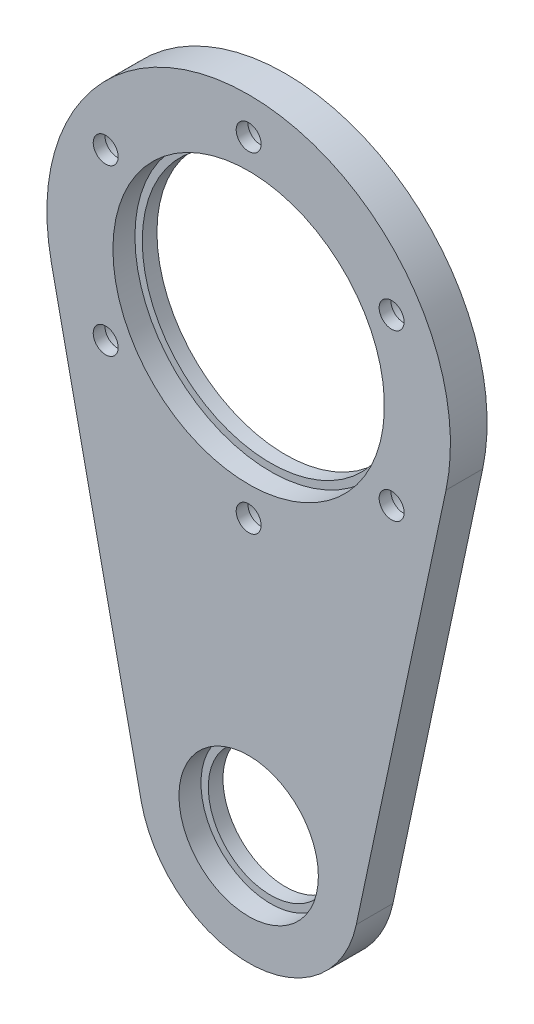
from build123d import *

# Parameters (mm, degrees)
SKETCH_2_R                   = 27.5
EXTRUDE_2_DEPTH              = 2
SKETCH_22_R                  = 10
CUT_EXTRUDE_1_DEPTH          = 2
FILLET_4_R                   = 0.2
SKETCH_54_R                  = 27.5
EXTRUDE_6_DEPTH              = 11
SKETCH_55_R                  = 18.5
CUT_EXTRUDE_2_DEPTH          = 8
HOLE_WIZARD_M4_1_D           = 4.5
HOLE_WIZARD_M4_1_CBORE_D     = 8
HOLE_WIZARD_M4_1_CBORE_DEPTH = 1
PATTERN_CIRCULAR_1_COUNT     = 3
SKETCH_59_R                  = 18.5
SKETCH_59_R_2                = 17.5
EXTRUDE_7_DEPTH              = 1
EXTRUDE_8_DEPTH              = 9
FILLET_6_R                   = 0.3
SKETCH_68_R                  = 9.5
CUT_EXTRUDE_7_DEPTH          = 7
SKETCH_69_R                  = 8.5
CUT_EXTRUDE_8_DEPTH          = 3
SKETCH_80_W                  = 72.028937147
SKETCH_80_H                  = 17.189961631
CUT_EXTRUDE_9_DEPTH          = 176.5
SKETCH_83_R                  = 18.5
SKETCH_83_R_2                = 17.5
EXTRUDE_9_DEPTH              = 2
PATTERN_CIRCULAR_2_COUNT     = 6


with BuildPart() as part:
    # 스케치2 → 보스-돌출2 (new body)
    with BuildSketch(Plane(origin=(0, 6, 0), x_dir=(1, 0, 0), z_dir=(0, 0, -1))):
        with Locations((0, 6)):
            Circle(SKETCH_2_R)
    extrude(amount=EXTRUDE_2_DEPTH)

    # 스케치22 → 컷-돌출1 (cut)
    with BuildSketch(Plane.XY):
        Circle(SKETCH_22_R)
    extrude(amount=-CUT_EXTRUDE_1_DEPTH, mode=Mode.SUBTRACT)

    # 필렛4
    fillet_4_edges = [part.edges().sort_by_distance(p)[0] for p in [
        (-10, 0, 0),
    ]]
    fillet(fillet_4_edges, radius=FILLET_4_R)

    # 스케치54 → 보스-돌출6 (add)
    with BuildSketch(Plane(origin=(0, 0, -2), x_dir=(-1, 0, 0), z_dir=(0, 0, -1))):
        Circle(SKETCH_54_R)
    extrude(amount=EXTRUDE_6_DEPTH)

    # 스케치55 → 컷-돌출2 (cut)
    with BuildSketch(Plane(origin=(0, 0, -13), x_dir=(-1, 0, 0), z_dir=(0, 0, -1))):
        Circle(SKETCH_55_R)
    extrude(amount=-CUT_EXTRUDE_2_DEPTH, mode=Mode.SUBTRACT)

    # M4 육각 소켓 머리 캡 나사용 카운터보어1 (through all)
    with Locations(Plane(origin=(0, 0, -5), x_dir=(-1, 0, 0), z_dir=(0, 0, -1))):
        with Locations((0, 6)):
            hole_wizard_m4_1 = CounterBoreHole(HOLE_WIZARD_M4_1_D / 2, HOLE_WIZARD_M4_1_CBORE_D / 2, HOLE_WIZARD_M4_1_CBORE_DEPTH)

    # 원형 패턴1: M4 육각 소켓 머리 캡 나사용 카운터보어1 ×3 about axis
    pattern_circular_1_axis = Axis((0, 0, 0), (0, 0, 1))
    for i in range(1, PATTERN_CIRCULAR_1_COUNT):
        add(hole_wizard_m4_1.rotate(pattern_circular_1_axis, i * 360 / PATTERN_CIRCULAR_1_COUNT), mode=Mode.SUBTRACT)

    # 스케치59 → 보스-돌출7 (add)
    with BuildSketch(Plane(origin=(0, 0, -5), x_dir=(-1, 0, 0), z_dir=(0, 0, -1))):
        Circle(SKETCH_59_R)
        Circle(SKETCH_59_R_2, mode=Mode.SUBTRACT)
    extrude(amount=EXTRUDE_7_DEPTH)

    # 스케치60 → 보스-돌출8 (add)
    with BuildSketch(Plane(origin=(0, 0, -13), x_dir=(-1, 0, 0), z_dir=(0, 0, -1))):
        with BuildLine():
            Line((-26.896591779, -5.729166667), (-14.670868243, -63.125))
            ThreePointArc((-14.670868243, -63.125), (0, -75), (14.670868243, -63.125))
            Line((14.670868243, -63.125), (26.896591779, -5.729166667))
            ThreePointArc((26.896591779, -5.729166667), (0, -27.5), (-26.896591779, -5.729166667))
        make_face()
    extrude(amount=-EXTRUDE_8_DEPTH)

    # 필렛6
    fillet_6_edges = [part.edges().sort_by_distance(p)[0] for p in [
        (18.5, 0, -6),
    ]]
    fillet(fillet_6_edges, radius=FILLET_6_R)

    # 스케치68 → 컷-돌출7 (cut)
    with BuildSketch(Plane.XY.offset(-4)):
        with Locations((0, -60)):
            Circle(SKETCH_68_R)
    extrude(amount=-CUT_EXTRUDE_7_DEPTH, mode=Mode.SUBTRACT)

    # 스케치69 → 컷-돌출8 (cut, through all)
    with BuildSketch(Plane.XY.offset(-11)):
        with Locations((0, -60)):
            Circle(SKETCH_69_R)
    extrude(amount=-CUT_EXTRUDE_8_DEPTH, mode=Mode.SUBTRACT)

    # 스케치80 → 컷-돌출9 (cut, symmetric)
    with BuildSketch(Plane(origin=(0, 0, 0), x_dir=(1, 0, 0), z_dir=(0, 1, 0))):
        with Locations((0.446829634, -0.594980816)):
            Rectangle(SKETCH_80_W, SKETCH_80_H)
    extrude(amount=CUT_EXTRUDE_9_DEPTH, both=True, mode=Mode.SUBTRACT)

    # 스케치83 → 보스-돌출9 (add)
    with BuildSketch(Plane(origin=(0, 0, -13), x_dir=(-1, 0, 0), z_dir=(0, 0, -1))):
        Circle(SKETCH_83_R)
        Circle(SKETCH_83_R_2, mode=Mode.SUBTRACT)
    extrude(amount=-EXTRUDE_9_DEPTH)

    # 스케치89 → M3 육각 소켓 머리 캡 나사용 카운터보어1 (revolve, cut)
    with BuildSketch(Plane(origin=(0, 22.5, -13), x_dir=(0, 1, 0), z_dir=(1, 0, 0))):
        Polygon((0, 0), (0, 223.021463052), (1.7, 222), (1.7, 3.4), (3.25, 3.4), (3.25, 0), align=None)
    hole_wizard_m3_1 = revolve(axis=Axis((0, 22.5, -19.35), (0, 0, 1)), mode=Mode.SUBTRACT)

    # 원형 패턴2: M3 육각 소켓 머리 캡 나사용 카운터보어1 ×6 about axis
    pattern_circular_2_axis = Axis((0, 0, 0), (0, 0, 1))
    for i in range(1, PATTERN_CIRCULAR_2_COUNT):
        add(hole_wizard_m3_1.rotate(pattern_circular_2_axis, i * 360 / PATTERN_CIRCULAR_2_COUNT), mode=Mode.SUBTRACT)


solid = part.part
